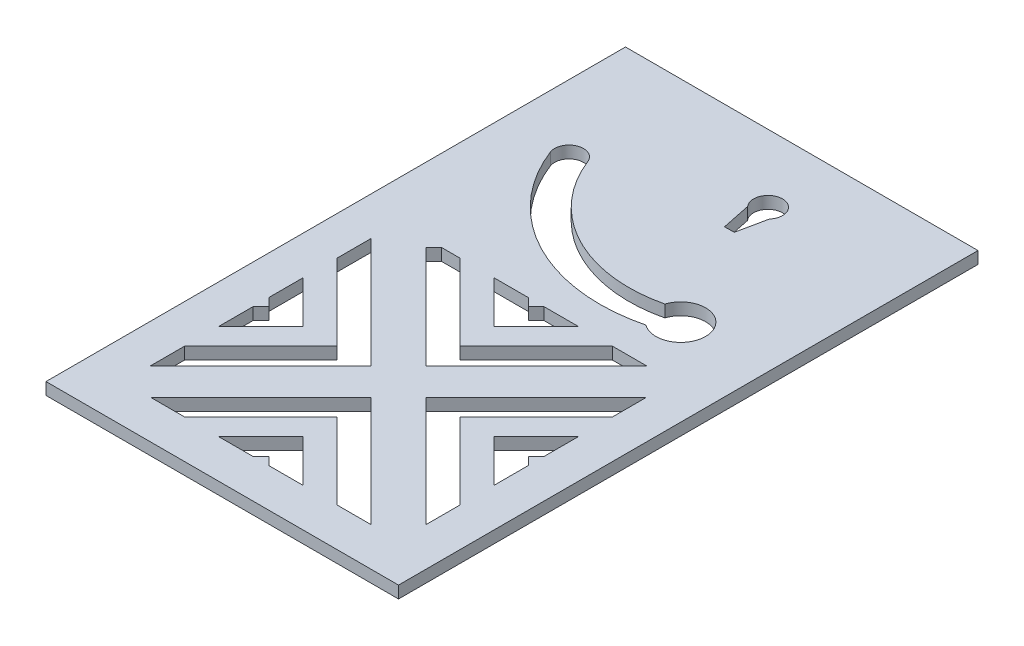
from build123d import *

# Parameters (mm, degrees)
IZIM1_W                     = 73
IZIM1_H                     = 120
Y_KSEKLIK_EKSTR_ZYON1_DEPTH = 2.5
KES_EKSTR_ZYON2_DEPTH       = 3.5
IZIM5_R                     = 3
KES_EKSTR_ZYON3_DEPTH       = 3.5
IZIM6_R                     = 5.15
KES_EKSTR_ZYON4_DEPTH       = 3.5
KES_EKSTR_ZYON5_DEPTH       = 3.5


with BuildPart() as part:
    # Çizim1 → Yükseklik-Ekstrüzyon1 (new body)
    with BuildSketch(Plane(origin=(0, 0, 0), x_dir=(1, 0, 0), z_dir=(0, 1, 0))):
        with Locations((36.5, 60)):
            Rectangle(IZIM1_W, IZIM1_H)
    extrude(amount=Y_KSEKLIK_EKSTR_ZYON1_DEPTH)

    # Çizim4 → Kes-Ekstrüzyon2 (cut, through all)
    with BuildSketch(Plane.XZ):
        with BuildLine():
            Line((41.258359694, -104.027018589), (42.500062903, -98.009051571))
            Line((42.500062903, -98.009051571), (44.499937097, -98.031483944))
            Line((44.499937097, -98.031483944), (45.758359694, -104.045976978))
            ThreePointArc((45.758359694, -104.045976978), (43.487361186, -109.020744393), (41.258359694, -104.027018589))
        make_face()
    extrude(amount=-KES_EKSTR_ZYON2_DEPTH, mode=Mode.SUBTRACT)

    # Çizim5 → Kes-Ekstrüzyon3 (cut, through all)
    with BuildSketch(Plane.XZ):
        with Locations((13.856266363, -94.455359404)):
            Circle(IZIM5_R)
        with BuildLine():
            ThreePointArc((53.975019366, -79.171862015), (52.270586975, -75.286645133), (56.155803858, -73.582212742))
            ThreePointArc((56.155803858, -73.582212742), (29.511480202, -74.134241759), (11.061441726, -93.364967158))
            ThreePointArc((11.061441726, -93.364967158), (14.411030317, -91.507099417), (16.856266363, -94.455359404))
            ThreePointArc((16.856266363, -94.455359404), (16.804526351, -95.010123359), (16.651091, -95.54575165))
            ThreePointArc((16.651091, -95.54575165), (31.921911605, -79.628768168), (53.975019366, -79.171862015))
        make_face()
        with Locations((55.065411612, -76.377037379)):
            Circle(IZIM5_R)
    extrude(amount=-KES_EKSTR_ZYON3_DEPTH, mode=Mode.SUBTRACT)

    # Çizim6 → Kes-Ekstrüzyon4 (cut, through all)
    with BuildSketch(Plane.XZ):
        with Locations((55.065411612, -76.377037379)):
            Circle(IZIM6_R)
    extrude(amount=-KES_EKSTR_ZYON4_DEPTH, mode=Mode.SUBTRACT)

    # Çizim7 → Kes-Ekstrüzyon5 (cut, through all)
    with BuildSketch(Plane.XZ):
        Polygon((16.916738879, -65), (20.727922061, -65), (22.357864376, -63.370057685), (18.82233047, -59.834523779), (15.286796564, -63.370057685), align=None)
        Polygon((22.357864376, -63.370057685), (25.893398282, -59.834523779), (22.357864376, -56.298989873), (18.82233047, -59.834523779), align=None)
        Polygon((25.893398282, -59.834523779), (29.428932188, -56.298989873), (25.893398282, -52.763455967), (22.357864376, -56.298989873), align=None)
        Polygon((29.428932188, -56.298989873), (32.964466094, -52.763455967), (29.428932188, -49.227922061), (25.893398282, -52.763455967), align=None)
        Polygon((32.964466094, -52.763455967), (36.5, -49.227922061), (32.964466094, -45.692388155), (29.428932188, -49.227922061), align=None)
        Polygon((36.5, -49.227922061), (40.035533906, -45.692388155), (36.5, -42.156854249), (32.964466094, -45.692388155), align=None)
        Polygon((40.035533906, -52.763455967), (43.571067812, -49.227922061), (40.035533906, -45.692388155), (36.5, -49.227922061), align=None)
        Polygon((43.571067812, -56.298989873), (47.106601718, -52.763455967), (43.571067812, -49.227922061), (40.035533906, -52.763455967), align=None)
        Polygon((47.106601718, -59.834523779), (50.642135624, -56.298989873), (47.106601718, -52.763455967), (43.571067812, -56.298989873), align=None)
        Polygon((50.642135624, -63.370057685), (54.17766953, -59.834523779), (50.642135624, -56.298989873), (47.106601718, -59.834523779), align=None)
        Polygon((52.272077939, -65), (56.083261121, -65), (57.713203436, -63.370057685), (54.17766953, -59.834523779), (50.642135624, -63.370057685), align=None)
        Polygon((56.083261121, -65), (59.343145751, -65), (57.713203436, -63.370057685), align=None)
        Polygon((41.941125497, -65), (45.201010127, -65), (43.571067812, -63.370057685), align=None)
        Polygon((38.129942315, -65), (41.941125497, -65), (43.571067812, -63.370057685), (40.035533906, -59.834523779), (36.5, -63.370057685), align=None)
        Polygon((36.5, -63.370057685), (40.035533906, -59.834523779), (36.5, -56.298989873), (32.964466094, -59.834523779), align=None)
        Polygon((31.058874503, -65), (34.870057685, -65), (36.5, -63.370057685), (32.964466094, -59.834523779), (29.428932188, -63.370057685), align=None)
        Polygon((27.798989873, -65), (31.058874503, -65), (29.428932188, -63.370057685), align=None)
        Polygon((8, -52.272077939), (8, -59.343145751), (13.165476221, -54.17766953), (9.629942315, -50.642135624), align=None)
        Polygon((9.629942315, -50.642135624), (13.165476221, -54.17766953), (16.701010127, -50.642135624), (13.165476221, -47.106601718), align=None)
        Polygon((13.165476221, -47.106601718), (16.701010127, -50.642135624), (20.236544033, -47.106601718), (16.701010127, -43.571067812), align=None)
        Polygon((16.701010127, -43.571067812), (20.236544033, -47.106601718), (23.772077939, -43.571067812), (20.236544033, -40.035533906), align=None)
        Polygon((20.236544033, -40.035533906), (23.772077939, -43.571067812), (27.307611845, -40.035533906), (23.772077939, -36.5), align=None)
        Polygon((23.772077939, -36.5), (27.307611845, -40.035533906), (30.843145751, -36.5), (27.307611845, -32.964466094), align=None)
        Polygon((20.236544033, -32.964466094), (23.772077939, -36.5), (27.307611845, -32.964466094), (23.772077939, -29.428932188), align=None)
        Polygon((16.701010127, -29.428932188), (20.236544033, -32.964466094), (23.772077939, -29.428932188), (20.236544033, -25.893398282), align=None)
        Polygon((13.165476221, -25.893398282), (16.701010127, -29.428932188), (20.236544033, -25.893398282), (16.701010127, -22.357864376), align=None)
        Polygon((9.629942315, -22.357864376), (13.165476221, -25.893398282), (16.701010127, -22.357864376), (13.165476221, -18.82233047), align=None)
        Polygon((8, -16.916738879), (8, -20.727922061), (9.629942315, -22.357864376), (13.165476221, -18.82233047), (9.629942315, -15.286796564), align=None)
        Polygon((8, -13.656854249), (8, -16.916738879), (9.629942315, -15.286796564), align=None)
        Polygon((8, -41.941125497), (8, -45.201010127), (9.629942315, -43.571067812), align=None)
        Polygon((8, -38.129942315), (8, -41.941125497), (9.629942315, -43.571067812), (13.165476221, -40.035533906), (9.629942315, -36.5), align=None)
        Polygon((9.629942315, -36.5), (13.165476221, -40.035533906), (16.701010127, -36.5), (13.165476221, -32.964466094), align=None)
        Polygon((8, -31.058874503), (8, -34.870057685), (9.629942315, -36.5), (13.165476221, -32.964466094), (9.629942315, -29.428932188), align=None)
        Polygon((8, -27.798989873), (8, -31.058874503), (9.629942315, -29.428932188), align=None)
        Polygon((63.370057685, -57.713203436), (65, -59.343145751), (65, -56.083261121), align=None)
        Polygon((63.370057685, -57.713203436), (65, -56.083261121), (65, -52.272077939), (63.370057685, -50.642135624), (59.834523779, -54.17766953), align=None)
        Polygon((56.298989873, -50.642135624), (59.834523779, -54.17766953), (63.370057685, -50.642135624), (59.834523779, -47.106601718), align=None)
        Polygon((52.763455967, -47.106601718), (56.298989873, -50.642135624), (59.834523779, -47.106601718), (56.298989873, -43.571067812), align=None)
        Polygon((49.227922061, -43.571067812), (52.763455967, -47.106601718), (56.298989873, -43.571067812), (52.763455967, -40.035533906), align=None)
        Polygon((45.692388155, -40.035533906), (49.227922061, -43.571067812), (52.763455967, -40.035533906), (49.227922061, -36.5), align=None)
        Polygon((42.156854249, -36.5), (45.692388155, -40.035533906), (49.227922061, -36.5), (45.692388155, -32.964466094), align=None)
        Polygon((45.692388155, -32.964466094), (49.227922061, -36.5), (52.763455967, -32.964466094), (49.227922061, -29.428932188), align=None)
        Polygon((49.227922061, -29.428932188), (52.763455967, -32.964466094), (56.298989873, -29.428932188), (52.763455967, -25.893398282), align=None)
        Polygon((52.763455967, -25.893398282), (56.298989873, -29.428932188), (59.834523779, -25.893398282), (56.298989873, -22.357864376), align=None)
        Polygon((56.298989873, -22.357864376), (59.834523779, -25.893398282), (63.370057685, -22.357864376), (59.834523779, -18.82233047), align=None)
        Polygon((63.370057685, -22.357864376), (65, -20.727922061), (65, -13.656854249), (59.834523779, -18.82233047), align=None)
        Polygon((56.298989873, -36.5), (59.834523779, -40.035533906), (63.370057685, -36.5), (59.834523779, -32.964466094), align=None)
        Polygon((63.370057685, -43.571067812), (65, -41.941125497), (65, -38.129942315), (63.370057685, -36.5), (59.834523779, -40.035533906), align=None)
        Polygon((63.370057685, -36.5), (65, -34.870057685), (65, -31.058874503), (63.370057685, -29.428932188), (59.834523779, -32.964466094), align=None)
        Polygon((63.370057685, -29.428932188), (65, -31.058874503), (65, -27.798989873), align=None)
        Polygon((63.370057685, -43.571067812), (65, -45.201010127), (65, -41.941125497), align=None)
        Polygon((22.357864376, -9.629942315), (20.727922061, -8), (13.656854249, -8), (18.82233047, -13.165476221), align=None)
        Polygon((22.357864376, -16.701010127), (25.893398282, -13.165476221), (22.357864376, -9.629942315), (18.82233047, -13.165476221), align=None)
        Polygon((25.893398282, -20.236544033), (29.428932188, -16.701010127), (25.893398282, -13.165476221), (22.357864376, -16.701010127), align=None)
        Polygon((29.428932188, -23.772077939), (32.964466094, -20.236544033), (29.428932188, -16.701010127), (25.893398282, -20.236544033), align=None)
        Polygon((32.964466094, -27.307611845), (36.5, -23.772077939), (32.964466094, -20.236544033), (29.428932188, -23.772077939), align=None)
        Polygon((40.035533906, -27.307611845), (43.571067812, -23.772077939), (40.035533906, -20.236544033), (36.5, -23.772077939), align=None)
        Polygon((43.571067812, -23.772077939), (47.106601718, -20.236544033), (43.571067812, -16.701010127), (40.035533906, -20.236544033), align=None)
        Polygon((47.106601718, -20.236544033), (50.642135624, -16.701010127), (47.106601718, -13.165476221), (43.571067812, -16.701010127), align=None)
        Polygon((50.642135624, -16.701010127), (54.17766953, -13.165476221), (50.642135624, -9.629942315), (47.106601718, -13.165476221), align=None)
        Polygon((57.713203436, -9.629942315), (56.083261121, -8), (52.272077939, -8), (50.642135624, -9.629942315), (54.17766953, -13.165476221), align=None)
        Polygon((43.571067812, -9.629942315), (41.941125497, -8), (38.129942315, -8), (36.5, -9.629942315), (40.035533906, -13.165476221), align=None)
        Polygon((36.5, -16.701010127), (40.035533906, -13.165476221), (36.5, -9.629942315), (32.964466094, -13.165476221), align=None)
        Polygon((36.5, -9.629942315), (34.870057685, -8), (31.058874503, -8), (29.428932188, -9.629942315), (32.964466094, -13.165476221), align=None)
        Polygon((57.713203436, -9.629942315), (59.343145751, -8), (56.083261121, -8), align=None)
        Polygon((29.428932188, -9.629942315), (31.058874503, -8), (27.798989873, -8), align=None)
        Polygon((36.5, -30.843145751), (40.035533906, -27.307611845), (36.5, -23.772077939), (32.964466094, -27.307611845), align=None)
        Polygon((43.571067812, -9.629942315), (45.201010127, -8), (41.941125497, -8), align=None)
    extrude(amount=-KES_EKSTR_ZYON5_DEPTH, mode=Mode.SUBTRACT)


solid = part.part
